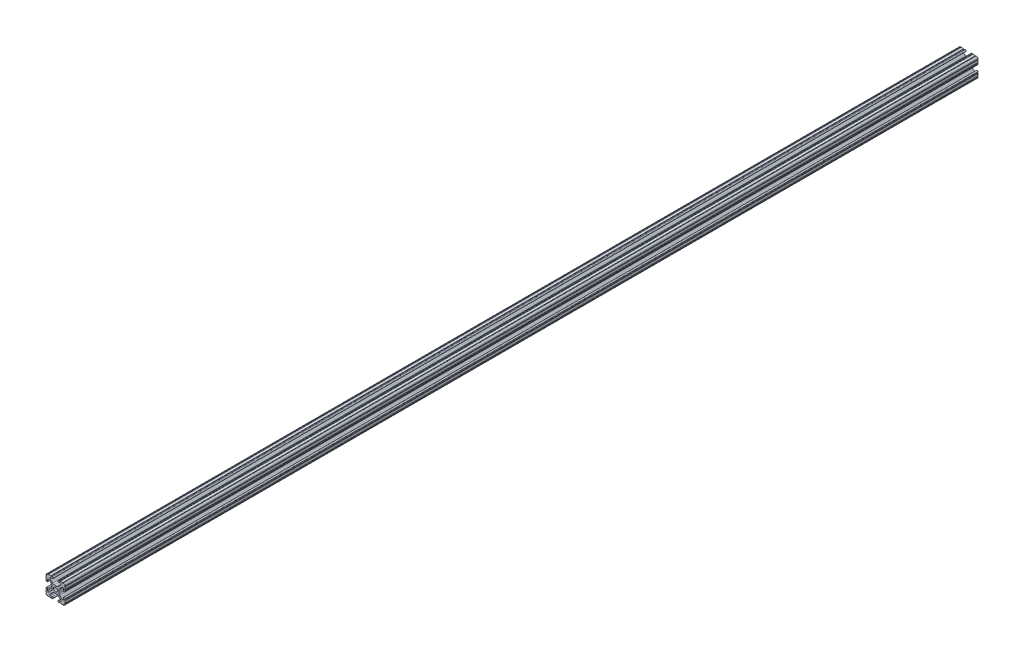
from build123d import *

# Parameters (mm, degrees)
SKETCH1_R           = 2.6035
BOSS_EXTRUDE1_DEPTH = 1219.2


with BuildPart() as part:
    # Sketch1 → Boss-Extrude1 (new body)
    with BuildSketch(Plane.XY):
        with BuildLine():
            Line((-12.7, 9.5504), (-12.7, 6.3330836))
            ThreePointArc((-12.7, 6.3330836), (-12.191999975, 5.8250836), (-12.7, 5.3170836))
            Line((-12.7, 5.3170836), (-12.7, 4.3434))
            ThreePointArc((-12.7, 4.3434), (-11.5951, 3.238499971), (-10.4902, 4.3434))
            Line((-10.4902, 4.3434), (-10.4902, 6.474794456))
            ThreePointArc((-10.4902, 6.474794456), (-9.863006367, 7.413456061), (-8.75577951, 7.193214945))
            Line((-8.75577951, 7.193214945), (-5.42573597, 3.863171405))
            ThreePointArc((-5.42573597, 3.863171405), (-4.737482484, 2.833127272), (-4.4958, 1.618107374))
            Line((-4.4958, 1.618107374), (-4.4958, -1.618107374))
            ThreePointArc((-4.4958, -1.618107374), (-4.737482484, -2.833127272), (-5.42573597, -3.863171405))
            Line((-5.42573597, -3.863171405), (-8.75577951, -7.193214945))
            ThreePointArc((-8.75577951, -7.193214945), (-9.863006367, -7.413456061), (-10.4902, -6.474794456))
            Line((-10.4902, -6.474794456), (-10.4902, -4.3434))
            ThreePointArc((-10.4902, -4.3434), (-11.5951, -3.2385), (-12.7, -4.3434))
            Line((-12.7, -4.3434), (-12.7, -5.3170836))
            ThreePointArc((-12.7, -5.3170836), (-12.191999983, -5.8250836), (-12.7, -6.3330836))
            Line((-12.7, -6.3330836), (-12.7, -9.5504))
            ThreePointArc((-12.7, -9.5504), (-12.192000006, -10.058323491), (-12.699846982, -10.566399977))
            ThreePointArc((-12.699846982, -10.566399977), (-12.082522516, -12.082522516), (-10.566399977, -12.699846982))
            ThreePointArc((-10.566399977, -12.699846982), (-10.058323491, -12.192000006), (-9.5504, -12.7))
            Line((-9.5504, -12.7), (-6.3330836, -12.7))
            ThreePointArc((-6.3330836, -12.7), (-5.8250836, -12.191999983), (-5.3170836, -12.7))
            Line((-5.3170836, -12.7), (-4.3434, -12.7))
            ThreePointArc((-4.3434, -12.7), (-3.238499971, -11.5951), (-4.3434, -10.4902))
            Line((-4.3434, -10.4902), (-6.474794456, -10.4902))
            ThreePointArc((-6.474794456, -10.4902), (-7.413456061, -9.863006367), (-7.193214945, -8.75577951))
            Line((-7.193214945, -8.75577951), (-3.863171405, -5.42573597))
            ThreePointArc((-3.863171405, -5.42573597), (-2.833127272, -4.737482484), (-1.618107374, -4.4958))
            Line((-1.618107374, -4.4958), (1.618107374, -4.4958))
            ThreePointArc((1.618107374, -4.4958), (2.833127272, -4.737482484), (3.863171405, -5.42573597))
            Line((3.863171405, -5.42573597), (7.193214945, -8.75577951))
            ThreePointArc((7.193214945, -8.75577951), (7.413456061, -9.863006367), (6.474794456, -10.4902))
            Line((6.474794456, -10.4902), (4.3434, -10.4902))
            ThreePointArc((4.3434, -10.4902), (3.2385, -11.5951), (4.3434, -12.7))
            Line((4.3434, -12.7), (5.3170836, -12.7))
            ThreePointArc((5.3170836, -12.7), (5.8250836, -12.191999983), (6.3330836, -12.7))
            Line((6.3330836, -12.7), (9.5504, -12.7))
            ThreePointArc((9.5504, -12.7), (10.058323491, -12.192000006), (10.566399977, -12.699846982))
            ThreePointArc((10.566399977, -12.699846982), (12.082522516, -12.082522516), (12.699846982, -10.566399977))
            ThreePointArc((12.699846982, -10.566399977), (12.192000006, -10.058323491), (12.7, -9.5504))
            Line((12.7, -9.5504), (12.7, -6.3330836))
            ThreePointArc((12.7, -6.3330836), (12.191999983, -5.8250836), (12.7, -5.3170836))
            Line((12.7, -5.3170836), (12.7, -4.3434))
            ThreePointArc((12.7, -4.3434), (11.5951, -3.238499971), (10.4902, -4.3434))
            Line((10.4902, -4.3434), (10.4902, -6.474794456))
            ThreePointArc((10.4902, -6.474794456), (9.863006367, -7.413456061), (8.75577951, -7.193214945))
            Line((8.75577951, -7.193214945), (5.42573597, -3.863171405))
            ThreePointArc((5.42573597, -3.863171405), (4.737482484, -2.833127272), (4.4958, -1.618107374))
            Line((4.4958, -1.618107374), (4.4958, 1.618107374))
            ThreePointArc((4.4958, 1.618107374), (4.737482484, 2.833127272), (5.42573597, 3.863171405))
            Line((5.42573597, 3.863171405), (8.75577951, 7.193214945))
            ThreePointArc((8.75577951, 7.193214945), (9.863006367, 7.413456061), (10.4902, 6.474794456))
            Line((10.4902, 6.474794456), (10.4902, 4.3434))
            ThreePointArc((10.4902, 4.3434), (11.5951, 3.2385), (12.7, 4.3434))
            Line((12.7, 4.3434), (12.7, 5.3170836))
            ThreePointArc((12.7, 5.3170836), (12.191999983, 5.8250836), (12.7, 6.3330836))
            Line((12.7, 6.3330836), (12.7, 9.5504))
            ThreePointArc((12.7, 9.5504), (12.192000006, 10.058323491), (12.699846982, 10.566399977))
            ThreePointArc((12.699846982, 10.566399977), (12.082522516, 12.082522516), (10.566399977, 12.699846982))
            ThreePointArc((10.566399977, 12.699846982), (10.058323491, 12.192000006), (9.5504, 12.7))
            Line((9.5504, 12.7), (6.3330836, 12.7))
            ThreePointArc((6.3330836, 12.7), (5.8250836, 12.192), (5.3170836, 12.7))
            Line((5.3170836, 12.7), (4.3434, 12.7))
            ThreePointArc((4.3434, 12.7), (3.238499971, 11.5951), (4.3434, 10.4902))
            Line((4.3434, 10.4902), (6.474794456, 10.4902))
            ThreePointArc((6.474794456, 10.4902), (7.413456061, 9.863006367), (7.193214945, 8.75577951))
            Line((7.193214945, 8.75577951), (3.863171405, 5.42573597))
            ThreePointArc((3.863171405, 5.42573597), (2.833127272, 4.737482484), (1.618107374, 4.4958))
            Line((1.618107374, 4.4958), (-1.618107374, 4.4958))
            ThreePointArc((-1.618107374, 4.4958), (-2.833127272, 4.737482484), (-3.863171405, 5.42573597))
            Line((-3.863171405, 5.42573597), (-7.193214945, 8.75577951))
            ThreePointArc((-7.193214945, 8.75577951), (-7.413456061, 9.863006367), (-6.474794456, 10.4902))
            Line((-6.474794456, 10.4902), (-4.3434, 10.4902))
            ThreePointArc((-4.3434, 10.4902), (-3.2385, 11.5951), (-4.3434, 12.7))
            Line((-4.3434, 12.7), (-5.3170836, 12.7))
            ThreePointArc((-5.3170836, 12.7), (-5.8250836, 12.191999983), (-6.3330836, 12.7))
            Line((-6.3330836, 12.7), (-9.5504, 12.7))
            ThreePointArc((-9.5504, 12.7), (-10.058323491, 12.192000006), (-10.566399977, 12.699846982))
            ThreePointArc((-10.566399977, 12.699846982), (-12.082522516, 12.082522516), (-12.699846982, 10.566399977))
            ThreePointArc((-12.699846982, 10.566399977), (-12.192000006, 10.058323491), (-12.7, 9.5504))
        make_face()
        Circle(SKETCH1_R, mode=Mode.SUBTRACT)
    extrude(amount=-BOSS_EXTRUDE1_DEPTH)


solid = part.part
